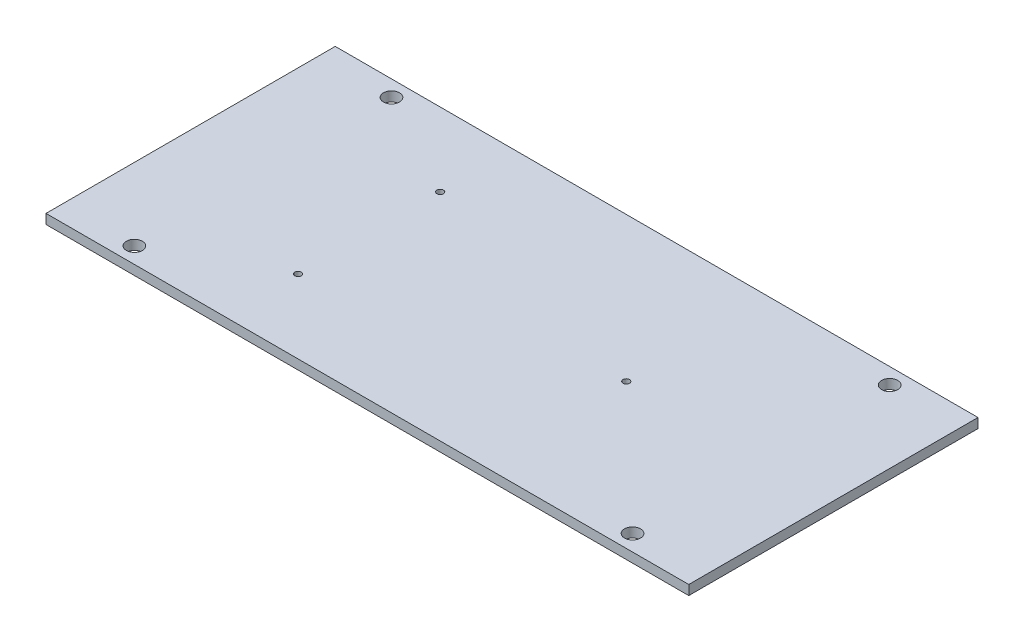
from build123d import *

# Parameters (mm, degrees)
SKETCH1_W           = 200
SKETCH1_H           = 90
BOSS_EXTRUDE1_DEPTH = 3
SKETCH2_R           = 2.5
CUT_EXTRUDE1_DEPTH  = 4
SKETCH3_R           = 1.016
CUT_EXTRUDE2_DEPTH  = 4


with BuildPart() as part:
    # Sketch1 → Boss-Extrude1 (new body)
    with BuildSketch(Plane(origin=(0, 0, 0), x_dir=(1, 0, 0), z_dir=(0, 1, 0))):
        Rectangle(SKETCH1_W, SKETCH1_H)
    extrude(amount=BOSS_EXTRUDE1_DEPTH)

    # Sketch2 → Cut-Extrude1 (cut, through all)
    with BuildSketch(Plane(origin=(0, 3, 0), x_dir=(1, 0, 0), z_dir=(0, 1, 0))):
        with Locations((-77.5, 40)):
            Circle(SKETCH2_R)
        with Locations((77.5, 40)):
            Circle(SKETCH2_R)
        with Locations((77.5, -40)):
            Circle(SKETCH2_R)
        with Locations((-77.5, -40)):
            Circle(SKETCH2_R)
    extrude(amount=-CUT_EXTRUDE1_DEPTH, mode=Mode.SUBTRACT)

    # Sketch3 → Cut-Extrude2 (cut, through all)
    with BuildSketch(Plane(origin=(0, 3, 0), x_dir=(1, 0, 0), z_dir=(0, 1, 0))):
        with Locations((-44.45, 22.098)):
            Circle(SKETCH3_R)
        with Locations((-44.45, -22.098)):
            Circle(SKETCH3_R)
        with Locations((35.56, 0)):
            Circle(SKETCH3_R)
    extrude(amount=-CUT_EXTRUDE2_DEPTH, mode=Mode.SUBTRACT)


solid = part.part
